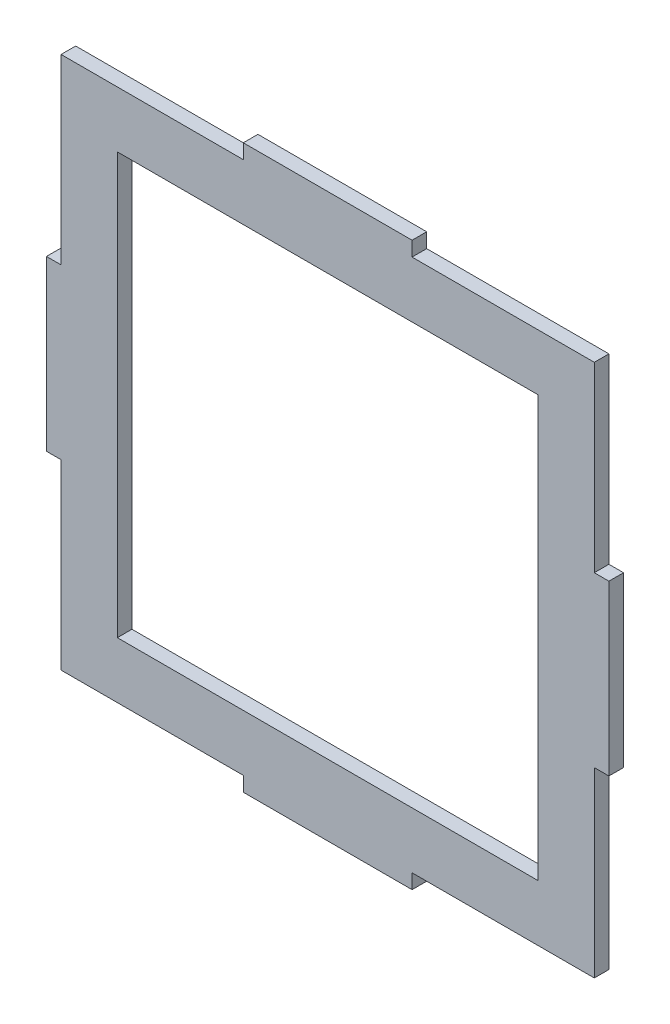
from build123d import *

# Parameters (mm, degrees)
BOSS_EXTRUDE2_DEPTH = 2.6
SKETCH4_W           = 74.8
SKETCH4_H           = 74.8
CUT_EXTRUDE1_DEPTH  = 3.6


with BuildPart() as part:
    # Sketch3 → Boss-Extrude2 (new body)
    with BuildSketch(Plane.XY):
        Polygon((62.4, 94.8), (94.8, 94.8), (94.8, 62.4), (97.4, 62.4), (97.4, 32.4), (94.8, 32.4), (94.8, 0), (62.4, 0), (62.4, -2.6), (32.4, -2.6), (32.4, 0), (0, 0), (0, 32.4), (-2.6, 32.4), (-2.6, 62.4), (0, 62.4), (0, 94.8), (32.4, 94.8), (32.4, 97.4), (62.4, 97.4), align=None)
    extrude(amount=BOSS_EXTRUDE2_DEPTH)

    # Sketch4 → Cut-Extrude1 (cut, through all)
    with BuildSketch(Plane.XY.offset(2.6)):
        with Locations((47.4, 47.4)):
            Rectangle(SKETCH4_W, SKETCH4_H)
    extrude(amount=-CUT_EXTRUDE1_DEPTH, mode=Mode.SUBTRACT)


solid = part.part
